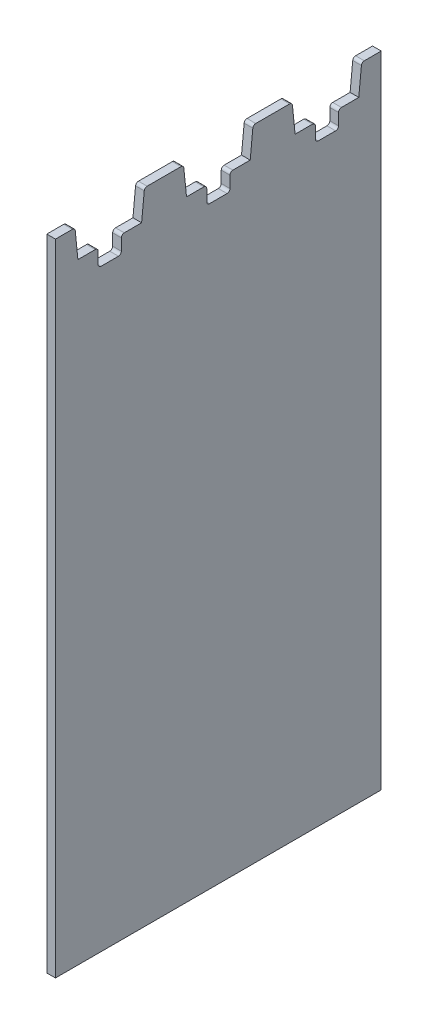
from build123d import *

# Parameters (mm, degrees)
BOSS_EXTRUDE2_DEPTH    = 3
FILLET1_R              = 1
LPATTERN1_COUNT        = 3
LPATTERN1_PITCH        = 37.5
FILLET1_OF_LPATTERN1_R = 1


with BuildPart() as part:
    # Sketch2 → Boss-Extrude2 (new body)
    with BuildSketch(Plane(origin=(0, 0, 0), x_dir=(0, 0, -1), z_dir=(1, 0, 0))):
        Polygon((-4, 102), (-4, 108), (-11, 108), (-12, 118), (-18.75, 118), (-18.75, -103), (18.75, -103), (18.75, 118), (12, 118), (11, 108), (4, 108), (4, 102), align=None)
    boss_extrude2 = extrude(amount=BOSS_EXTRUDE2_DEPTH)

    # Fillet1
    fillet1_edges = [part.edges().sort_by_distance(p)[0] for p in [
        (1.5, 108, -4),
        (1.5, 118, -12),
        (1.5, 118, 12),
        (1.5, 108, 4),
        (1.5, 102, 4),
        (1.5, 102, -4),
    ]]
    fillet(fillet1_edges, radius=FILLET1_R)

    # LPattern1: Boss-Extrude2 ×3
    with Locations(*[(0, 0, i * LPATTERN1_PITCH) for i in range(1, LPATTERN1_COUNT)]):
        add(boss_extrude2)

    # Fillet1 of LPattern1
    fillet1_of_lpattern1_edges = [part.edges().sort_by_distance(p)[0] for p in [
        (1.5, 108, 33.5),
        (1.5, 118, 25.5),
        (1.5, 118, 49.5),
        (1.5, 108, 41.5),
        (1.5, 102, 41.5),
        (1.5, 102, 33.5),
        (1.5, 108, 71),
        (1.5, 118, 63),
        (1.5, 118, 87),
        (1.5, 108, 79),
        (1.5, 102, 79),
        (1.5, 102, 71),
    ]]
    fillet(fillet1_of_lpattern1_edges, radius=FILLET1_OF_LPATTERN1_R)


solid = part.part
